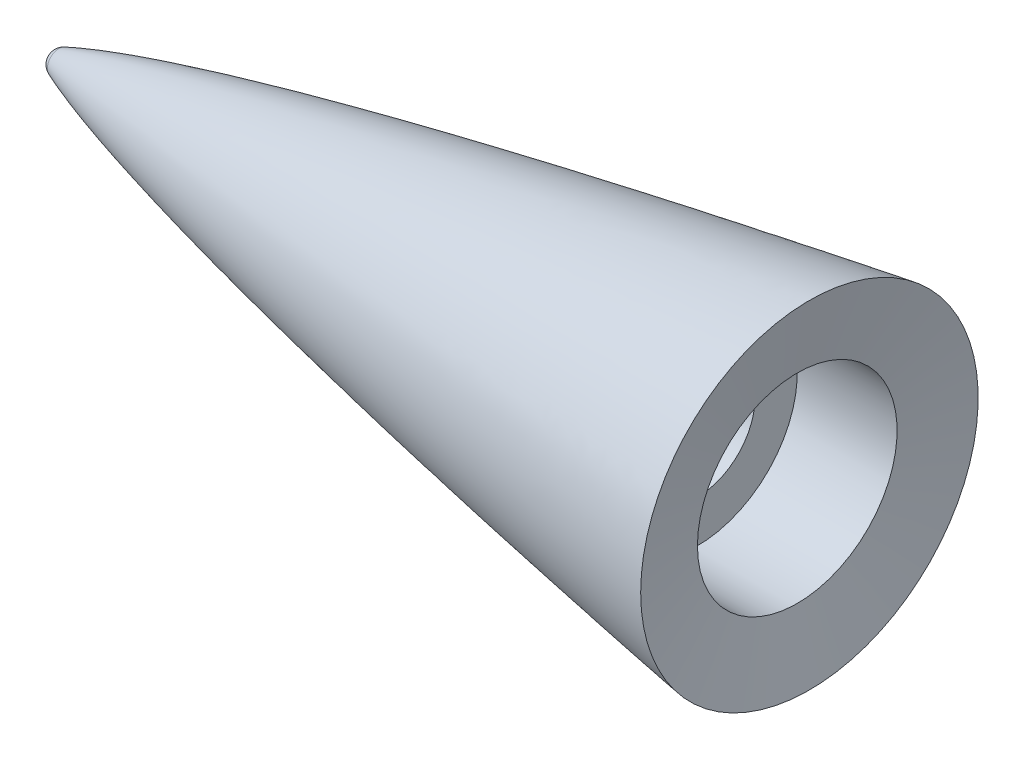
from build123d import *

# Parameters (mm, degrees)
TAPPED_HOLE_FOR_9_16_12_HELICOIL1_D     = 14.68374
TAPPED_HOLE_FOR_9_16_12_HELICOIL1_DEPTH = 27.94
TAPPED_HOLE_FOR_9_16_12_HELICOIL1_TIP   = 4.411440553


with BuildPart() as part:
    # Sketch1 → Revolve2 (revolve)
    with BuildSketch(Plane(origin=(0, 0, 0), x_dir=(1, 0, 0), z_dir=(0, 1, 0))):
        with BuildLine():
            Line((1.697321091, 0), (45.819405393, 0))
            Line((45.819405393, 0), (83.919405393, 0))
            Line((83.919405393, 0), (83.919405393, 7.68858))
            Line((83.919405393, 7.68858), (83.919405393, 12.7))
            Line((83.919405393, 12.7), (96.619405393, 12.7))
            Line((96.619405393, 12.7), (98.165428581, 21.4679332))
            add(Edge.make_bspline(
                [(2.682127148, 1.468644362), (2.982092127, 1.591742283), (3.982765764, 1.986976913), (6.075542743, 2.735585346), (9.959285205, 3.961402854), (15.35260807, 5.458934046), (21.847317263, 7.086678944), (29.055363889, 8.749177841), (36.286920774, 10.313744718), (43.531901048, 11.801111844), (50.793776988, 13.226984496), (58.058153921, 14.599266319), (64.433980883, 15.762645369), (69.883896781, 16.732062359), (74.459068804, 17.529825957), (78.065425347, 18.150661812), (81.784961377, 18.781283529), (85.307065103, 19.372441088), (89.168740248, 20.010357493), (92.45838759, 20.54964543), (95.664328261, 21.067043036), (97.333372349, 21.334925019), (98.164963492, 21.467858845), (98.165428581, 21.4679332)],
                knots=[0.027847292, 0.027847292, 0.027847292, 0.027847292, 0.027847292, 0.039565322, 0.06672611, 0.108155752, 0.174993972, 0.2418322, 0.308670423, 0.375508647, 0.442346873, 0.509185099, 0.576023325, 0.642861549, 0.676280662, 0.709699776, 0.743118888, 0.776538001, 0.809957114, 0.843376227, 0.87679534, 0.910214452, 0.910233153, 0.910233153, 0.910233153, 0.910233153, 0.910233153], degree=4))
            ThreePointArc((2.682127148, 1.468644362), (1.966311917, 0.884132234), (1.697321091, 0))
        make_face()
    revolve(axis=Axis((0, 0, 0), (1, 0, 0)))

    # Tapped Hole for 9/16-12 Helicoil1
    with Locations(Plane(origin=(83.919405393, 0, 0), x_dir=(0, 0, -1), z_dir=(1, 0, 0))):
        with Locations((0, 0)):
            Hole(TAPPED_HOLE_FOR_9_16_12_HELICOIL1_D / 2, depth=TAPPED_HOLE_FOR_9_16_12_HELICOIL1_DEPTH)
            with Locations((0, 0, -(TAPPED_HOLE_FOR_9_16_12_HELICOIL1_DEPTH + TAPPED_HOLE_FOR_9_16_12_HELICOIL1_TIP / 2))):  # 118° drill point
                Cone(0, TAPPED_HOLE_FOR_9_16_12_HELICOIL1_D / 2, TAPPED_HOLE_FOR_9_16_12_HELICOIL1_TIP, mode=Mode.SUBTRACT)


solid = part.part
